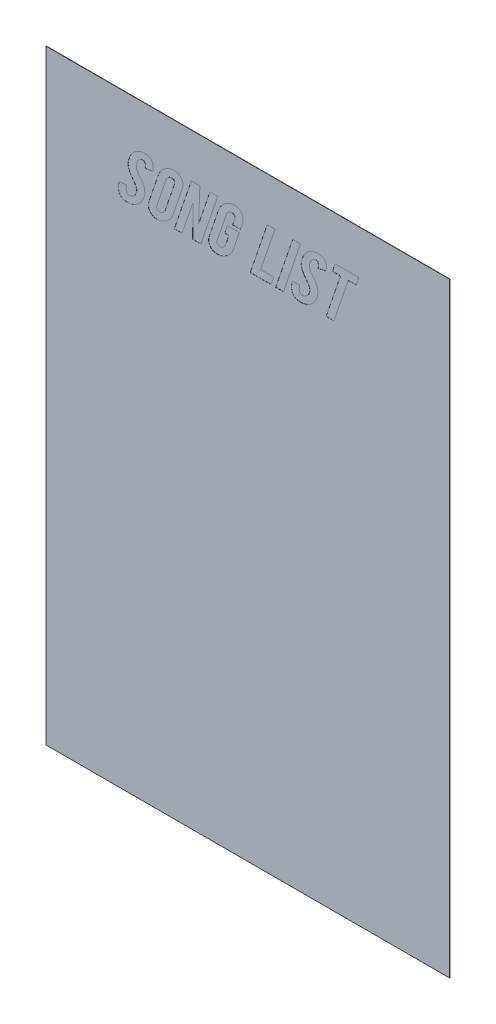
from build123d import *

# Parameters (mm, degrees)
SKETCH1_W           = 101.6
SKETCH1_H           = 152.4
BOSS_EXTRUDE1_DEPTH = 0.0762
CUT_EXTRUDE1_DEPTH  = 0.0254


with BuildPart() as part:
    # Sketch1 → Boss-Extrude1 (new body)
    with BuildSketch(Plane.XY):
        with Locations((50.8, 76.2)):
            Rectangle(SKETCH1_W, SKETCH1_H)
    extrude(amount=BOSS_EXTRUDE1_DEPTH)

    # Sketch2 → Cut-Extrude1 (cut)
    with BuildSketch(Plane.XY.offset(0.0762)):
        with BuildLine():
            add(Edge.make_bspline(
                [(24.709722411, 131.874145335), (24.672291046, 131.766544496), (24.597928769, 131.55278143), (24.461285746, 131.242755215), (24.307043652, 130.943876771), (24.128986602, 130.658993247), (23.935272763, 130.383775362), (23.719477586, 130.121712166), (23.484484784, 129.871420354), (23.314362951, 129.716392222), (23.228761989, 129.638386024)],
                knots=[0, 0, 0, 0, 0.000341658, 0.000678748, 0.001015434, 0.001349782, 0.001685778, 0.002024428, 0.002367376, 0.002714706, 0.002714706, 0.002714706, 0.002714706], degree=3))
            add(Edge.make_bspline(
                [(23.228761989, 129.638386024), (23.10934454, 129.537251061), (22.869964872, 129.334519767), (22.460691013, 129.094560959), (22.023340585, 128.890784152), (21.711749675, 128.799195889), (21.55347665, 128.752673506)],
                knots=[0, 0, 0, 0, 0.000468644, 0.000939426, 0.001418175, 0.001912397, 0.001912397, 0.001912397, 0.001912397], degree=3))
            add(Edge.make_bspline(
                [(21.55347665, 128.752673506), (21.467917096, 128.729833286), (21.293573471, 128.683292056), (21.021073564, 128.644679529), (20.738071611, 128.612486987), (20.545138284, 128.610499342), (20.446847384, 128.609486725)],
                knots=[0, 0, 0, 0, 0.000265422, 0.000540847, 0.000824579, 0.001119248, 0.001119248, 0.001119248, 0.001119248], degree=3))
            add(Edge.make_bspline(
                [(20.446847384, 128.609486725), (20.356799544, 128.61104227), (20.181805119, 128.614065236), (19.927836709, 128.637789315), (19.692262255, 128.681604133), (19.473121254, 128.737554558), (19.272291642, 128.81338792), (19.089103677, 128.905683719), (18.923020893, 129.013557405), (18.827105376, 129.10045869), (18.779744146, 129.143368866)],
                knots=[0, 0, 0, 0, 0.000270133, 0.000524963, 0.000764089, 0.000988351, 0.001202625, 0.001406624, 0.00160292, 0.001794392, 0.001794392, 0.001794392, 0.001794392], degree=3))
            add(Edge.make_bspline(
                [(18.779744146, 129.143368866), (18.707378095, 129.220497062), (18.560563145, 129.376973367), (18.401671353, 129.667104482), (18.280793624, 129.991910818), (18.211947949, 130.357430793), (18.188226135, 130.757331338), (18.216030933, 131.189121219), (18.287130708, 131.651703684), (18.370305281, 131.964822015), (18.413595092, 132.12779049)],
                knots=[0, 0, 0, 0, 0.000316164, 0.000641429, 0.00098379, 0.001352859, 0.001752491, 0.002182752, 0.00264853, 0.003154073, 0.003154073, 0.003154073, 0.003154073], degree=3))
            Line((18.413595092, 132.12779049), (20.256613518, 132.250522017))
            add(Edge.make_bspline(
                [(20.256613518, 132.250522017), (20.237932262, 132.162738665), (20.202025077, 131.994010554), (20.165518772, 131.748154924), (20.143001479, 131.520708023), (20.142345912, 131.312227877), (20.151032737, 131.121862369), (20.185969642, 130.951807287), (20.229754682, 130.797203394), (20.278204673, 130.706851251), (20.301615077, 130.663194272)],
                knots=[0, 0, 0, 0, 0.000269179, 0.000517388, 0.000745361, 0.000954015, 0.001142603, 0.001315507, 0.001474019, 0.001622217, 0.001622217, 0.001622217, 0.001622217], degree=3))
            add(Edge.make_bspline(
                [(20.301615077, 130.663194272), (20.339454787, 130.606584239), (20.412463753, 130.4973593), (20.572073641, 130.380484078), (20.760124381, 130.313586549), (20.894241247, 130.312127021), (20.964365322, 130.311363895)],
                knots=[0, 0, 0, 0, 0.00020292, 0.000391519, 0.000582368, 0.000791502, 0.000791502, 0.000791502, 0.000791502], degree=3))
            add(Edge.make_bspline(
                [(20.964365322, 130.311363895), (21.016305969, 130.315074019), (21.120966108, 130.322549899), (21.27635593, 130.353301089), (21.429703091, 130.403676782), (21.581357025, 130.47124548), (21.73063418, 130.558128058), (21.878951527, 130.661518258), (22.025945289, 130.781272986), (22.11809148, 130.872404958), (22.165088758, 130.918884953)],
                knots=[0, 0, 0, 0, 0.000156118, 0.000314577, 0.000473708, 0.000639446, 0.00081172, 0.000991027, 0.001181437, 0.001379642, 0.001379642, 0.001379642, 0.001379642], degree=3))
            add(Edge.make_bspline(
                [(22.165088758, 130.918884953), (22.222825837, 130.971729851), (22.339933249, 131.078914513), (22.485143716, 131.275755913), (22.609309407, 131.500900011), (22.671071076, 131.665931804), (22.70306195, 131.751413809)],
                knots=[0, 0, 0, 0, 0.000234335, 0.0004753, 0.000729809, 0.001003299, 0.001003299, 0.001003299, 0.001003299], degree=3))
            add(Edge.make_bspline(
                [(22.70306195, 131.751413809), (22.723618225, 131.817166814), (22.76402491, 131.946414984), (22.798926778, 132.145617003), (22.81030961, 132.343769362), (22.804052605, 132.541701628), (22.76835204, 132.737073685), (22.718803151, 132.933360088), (22.641669513, 133.128011558), (22.576651507, 133.25404525), (22.543510965, 133.318286299)],
                knots=[0, 0, 0, 0, 0.000206517, 0.000405943, 0.000604738, 0.000801279, 0.00099834, 0.001199281, 0.001407825, 0.001624631, 0.001624631, 0.001624631, 0.001624631], degree=3))
            add(Edge.make_bspline(
                [(22.543510965, 133.318286299), (22.510046704, 133.365295129), (22.439393573, 133.464544926), (22.328966453, 133.622077145), (22.208419143, 133.796517836), (22.075386514, 133.986702508), (21.929523055, 134.193539575), (21.773267937, 134.41758172), (21.604226071, 134.657360594), (21.489891055, 134.823671724), (21.430745123, 134.909705096)],
                knots=[0, 0, 0, 0, 0.00017311, 0.000365487, 0.000577137, 0.00080923, 0.001061768, 0.001336425, 0.001628677, 0.001941883, 0.001941883, 0.001941883, 0.001941883], degree=3))
            add(Edge.make_bspline(
                [(21.430745123, 134.909705096), (21.381779815, 134.984358315), (21.286184469, 135.130104369), (21.155517314, 135.349322945), (21.038079304, 135.561486001), (20.937512275, 135.769258999), (20.851507888, 135.970424267), (20.781381067, 136.166510557), (20.725283414, 136.356287374), (20.698995076, 136.482516229), (20.686173861, 136.544079926)],
                knots=[0, 0, 0, 0, 0.000267808, 0.000522843, 0.000765434, 0.000995062, 0.001215039, 0.001421434, 0.001619523, 0.001808111, 0.001808111, 0.001808111, 0.001808111], degree=3))
            add(Edge.make_bspline(
                [(20.686173861, 136.544079926), (20.669193581, 136.682301366), (20.634541463, 136.9643736), (20.658565049, 137.401378763), (20.732997963, 137.854878595), (20.826295013, 138.154831093), (20.874362202, 138.309368385)],
                knots=[0, 0, 0, 0, 0.000417057, 0.000851098, 0.001307434, 0.001792396, 0.001792396, 0.001792396, 0.001792396], degree=3))
            add(Edge.make_bspline(
                [(20.874362202, 138.309368385), (20.925258473, 138.448724014), (21.025670371, 138.723655022), (21.213724616, 139.114101969), (21.423710668, 139.481128068), (21.664306807, 139.819480872), (21.931557007, 140.132134243), (22.224896018, 140.418368015), (22.542669714, 140.682083935), (22.774393589, 140.831723521), (22.891250291, 140.9071857)],
                knots=[0, 0, 0, 0, 0.000444839, 0.000877612, 0.00129828, 0.001712032, 0.002121158, 0.002530513, 0.002940405, 0.003357397, 0.003357397, 0.003357397, 0.003357397], degree=3))
            add(Edge.make_bspline(
                [(22.891250291, 140.9071857), (22.965050562, 140.94972695), (23.111526209, 141.034161018), (23.339382974, 141.143471632), (23.573541691, 141.232021399), (23.81101357, 141.309927877), (24.055174024, 141.365263017), (24.302679848, 141.409746361), (24.555809628, 141.434251684), (24.72603876, 141.437421611), (24.811998683, 141.439022316)],
                knots=[0, 0, 0, 0, 0.000255502, 0.00050711, 0.000757067, 0.001006126, 0.001256191, 0.001507399, 0.001760193, 0.002018059, 0.002018059, 0.002018059, 0.002018059], degree=3))
            add(Edge.make_bspline(
                [(24.811998683, 141.439022316), (24.893205462, 141.438314231), (25.051185496, 141.436936721), (25.28060847, 141.412766706), (25.496150091, 141.379168793), (25.698465172, 141.330511884), (25.886152558, 141.264467081), (26.061354516, 141.18718418), (26.222864484, 141.094969981), (26.320274825, 141.021431106), (26.368643547, 140.984915667)],
                knots=[0, 0, 0, 0, 0.000243495, 0.000473696, 0.000691273, 0.000897658, 0.001096906, 0.001287359, 0.001471559, 0.001653231, 0.001653231, 0.001653231, 0.001653231], degree=3))
            add(Edge.make_bspline(
                [(26.368643547, 140.984915667), (26.436575522, 140.922434887), (26.572744169, 140.797193082), (26.734631026, 140.564417454), (26.8526206, 140.295709815), (26.933294945, 139.995726646), (26.976347633, 139.667582489), (26.972812017, 139.314142258), (26.935740259, 138.936691714), (26.87748973, 138.681150537), (26.847296501, 138.548694862)],
                knots=[0, 0, 0, 0, 0.000276267, 0.000553773, 0.000843091, 0.001152743, 0.001482834, 0.001832619, 0.002210997, 0.00261818, 0.00261818, 0.00261818, 0.00261818], degree=3))
            Line((26.847296501, 138.548694862), (24.899956277, 138.21731974))
            add(Edge.make_bspline(
                [(24.899956277, 138.21731974), (24.913999891, 138.279952334), (24.941065273, 138.400660234), (24.97382945, 138.577746948), (24.988537105, 138.744778813), (24.996869977, 138.900530965), (24.988297184, 139.045811834), (24.967607837, 139.179724953), (24.93892277, 139.305094522), (24.905889362, 139.380938526), (24.88972865, 139.418043176)],
                knots=[0, 0, 0, 0, 0.000192584, 0.000371155, 0.000539684, 0.000695265, 0.000838686, 0.000975231, 0.00110174, 0.00122291, 0.00122291, 0.00122291, 0.00122291], degree=3))
            add(Edge.make_bspline(
                [(24.88972865, 139.418043176), (24.862909409, 139.466976012), (24.809400019, 139.564606151), (24.667571299, 139.668399548), (24.487880751, 139.727572008), (24.355687652, 139.733786797), (24.284253119, 139.737145145)],
                knots=[0, 0, 0, 0, 0.000165675, 0.000330552, 0.000512328, 0.000726044, 0.000726044, 0.000726044, 0.000726044], degree=3))
            add(Edge.make_bspline(
                [(24.284253119, 139.737145145), (24.203002006, 139.731652082), (24.039320075, 139.7205862), (23.801605668, 139.627352381), (23.575540714, 139.479436327), (23.444589099, 139.346493525), (23.376039821, 139.27690192)],
                knots=[0, 0, 0, 0, 0.000243065, 0.000489659, 0.00075575, 0.001048053, 0.001048053, 0.001048053, 0.001048053], degree=3))
            add(Edge.make_bspline(
                [(23.376039821, 139.27690192), (23.32209428, 139.212529568), (23.212338689, 139.081559973), (23.07245548, 138.861534392), (22.949568643, 138.61993396), (22.886712505, 138.447182658), (22.854430833, 138.358460996)],
                knots=[0, 0, 0, 0, 0.000251733, 0.000512166, 0.0007802, 0.0010632, 0.0010632, 0.0010632, 0.0010632], degree=3))
            add(Edge.make_bspline(
                [(22.854430833, 138.358460996), (22.83242993, 138.287261166), (22.788732805, 138.145847518), (22.750875969, 137.928184684), (22.733979251, 137.710317892), (22.74036262, 137.4916247), (22.769376017, 137.271690156), (22.820935676, 137.050530225), (22.894732311, 136.827846721), (22.960139554, 136.683313474), (22.993526563, 136.60953674)],
                knots=[0, 0, 0, 0, 0.000223375, 0.000443656, 0.000661098, 0.000878011, 0.001098748, 0.001325506, 0.001558373, 0.001801179, 0.001801179, 0.001801179, 0.001801179], degree=3))
            add(Edge.make_bspline(
                [(22.993526563, 136.60953674), (23.024694576, 136.550392158), (23.091499772, 136.423622271), (23.217897826, 136.231746159), (23.373944734, 136.026134909), (23.490639897, 135.886956055), (23.551955009, 135.813827342)],
                knots=[0, 0, 0, 0, 0.000200472, 0.000429689, 0.000688244, 0.000974508, 0.000974508, 0.000974508, 0.000974508], degree=3))
            add(Edge.make_bspline(
                [(23.551955009, 135.813827342), (23.623172786, 135.729529926), (23.753219455, 135.575599283), (23.925319915, 135.363574725), (24.056235625, 135.192434731), (24.124455005, 135.088651994), (24.15333949, 135.044709775)],
                knots=[0, 0, 0, 0, 0.000331047, 0.000604505, 0.000819285, 0.000977003, 0.000977003, 0.000977003, 0.000977003], degree=3))
            add(Edge.make_bspline(
                [(24.15333949, 135.044709775), (24.22437429, 134.930001758), (24.362888658, 134.706326763), (24.529711589, 134.358207861), (24.664388786, 134.01411493), (24.723615337, 133.780609339), (24.752678445, 133.666025625)],
                knots=[0, 0, 0, 0, 0.000404482, 0.000788719, 0.001156459, 0.001510784, 0.001510784, 0.001510784, 0.001510784], degree=3))
            add(Edge.make_bspline(
                [(24.752678445, 133.666025625), (24.77405358, 133.564759315), (24.815265684, 133.369513867), (24.831011465, 133.170609221), (24.838590514, 133.074868771)],
                knots=[0, 0, 0, 0, 0.000310118, 0.00059792, 0.00059792, 0.00059792, 0.00059792], degree=3))
            add(Edge.make_bspline(
                [(24.838590514, 133.074868771), (24.842443398, 132.96644533), (24.849936965, 132.755569909), (24.830831381, 132.446228323), (24.788269467, 132.152376245), (24.735582178, 131.965746306), (24.709722411, 131.874145335)],
                knots=[0, 0, 0, 0, 0.000325296, 0.000632677, 0.000928629, 0.001213904, 0.001213904, 0.001213904, 0.001213904], degree=3))
        make_face()
        with BuildLine():
            add(Edge.make_bspline(
                [(32.269984455, 141.439022316), (32.371731093, 141.436340493), (32.56859248, 141.43115165), (32.85312674, 141.389346359), (33.117209655, 141.322830623), (33.360545798, 141.226828116), (33.581554257, 141.1004222), (33.781610762, 140.947676563), (33.961942549, 140.768520757), (34.114958404, 140.561387484), (34.247013626, 140.338333738), (34.344821213, 140.098850448), (34.41372219, 139.849707942), (34.447770673, 139.58824844), (34.451411916, 139.315800587), (34.423589059, 139.032162488), (34.366746316, 138.737140762), (34.304614838, 138.541325995), (34.272553866, 138.440282013)],
                knots=[0, 0, 0, 0, 0.000305119, 0.000590351, 0.00086074, 0.001120554, 0.001372494, 0.001622057, 0.001873731, 0.002132286, 0.002392607, 0.002649399, 0.002905948, 0.003166019, 0.003438105, 0.003721637, 0.004019702, 0.004337496, 0.004337496, 0.004337496, 0.004337496], degree=3))
            Line((34.272553866, 138.440282013), (31.948836961, 131.608227027))
            add(Edge.make_bspline(
                [(31.948836961, 131.608227027), (31.91097918, 131.505249156), (31.835533171, 131.30002663), (31.692397686, 131.005185541), (31.529254349, 130.720530465), (31.337014554, 130.450786166), (31.123703789, 130.190530859), (30.888929653, 129.939864624), (30.626657525, 129.704584374), (30.346102828, 129.482217194), (30.052130933, 129.279440845), (29.752982239, 129.100799666), (29.452137865, 128.948177358), (29.147472982, 128.824962144), (28.841203602, 128.728163151), (28.531710814, 128.660676821), (28.221020363, 128.618285669), (28.012695051, 128.612412342), (27.908924207, 128.609486725)],
                knots=[0, 0, 0, 0, 0.000328967, 0.000655592, 0.000981878, 0.001312171, 0.001647943, 0.001990891, 0.002341351, 0.00270394, 0.003064237, 0.003411886, 0.003748529, 0.004075199, 0.004396737, 0.004710903, 0.005024503, 0.005335752, 0.005335752, 0.005335752, 0.005335752], degree=3))
            add(Edge.make_bspline(
                [(27.908924207, 128.609486725), (27.807849187, 128.612137306), (27.612325328, 128.617264703), (27.329292075, 128.659570444), (27.066793637, 128.724768059), (26.825574189, 128.822714757), (26.606498013, 128.947682652), (26.406717801, 129.098659108), (26.229467533, 129.278803637), (26.07587397, 129.484420597), (25.946312393, 129.708344848), (25.850240982, 129.947679492), (25.783911173, 130.197718816), (25.749482836, 130.459567687), (25.74608104, 130.732682312), (25.773079794, 131.016609065), (25.83330553, 131.311096502), (25.894996857, 131.50713383), (25.926810051, 131.608227027)],
                knots=[0, 0, 0, 0, 0.000303076, 0.000586284, 0.000856672, 0.00111269, 0.00136463, 0.001611326, 0.001861558, 0.002120113, 0.002379411, 0.002635429, 0.002891447, 0.003153546, 0.003425631, 0.003709163, 0.004007628, 0.004325423, 0.004325423, 0.004325423, 0.004325423], degree=3))
            Line((25.926810051, 131.608227027), (28.250526956, 138.440282013))
            add(Edge.make_bspline(
                [(28.250526956, 138.440282013), (28.288394934, 138.543252481), (28.363861264, 138.748460252), (28.506845224, 139.04341136), (28.670844068, 139.328131715), (28.86097267, 139.599454051), (29.076484085, 139.857993927), (29.310306427, 140.10874547), (29.572739834, 140.343901125), (29.853261609, 140.566279443), (30.147198018, 140.769139774), (30.445990493, 140.947137825), (30.745097879, 141.100430717), (31.047247716, 141.223054908), (31.350513488, 141.320747244), (31.656128061, 141.387324325), (31.962615048, 141.430397457), (32.167567327, 141.436148467), (32.269984455, 141.439022316)],
                knots=[0, 0, 0, 0, 0.000328967, 0.000655592, 0.000981878, 0.001313846, 0.001648037, 0.001990985, 0.002341445, 0.002704034, 0.003064331, 0.00341198, 0.003746797, 0.004071572, 0.004389209, 0.004701378, 0.005008894, 0.005316057, 0.005316057, 0.005316057, 0.005316057], degree=3))
        make_face()
        with BuildLine():
            add(Edge.make_bspline(
                [(32.298621812, 138.411644657), (32.319266947, 138.482655707), (32.358259109, 138.616773232), (32.369435888, 138.81856732), (32.337712718, 139.004877967), (32.258390811, 139.168552911), (32.145964234, 139.307431784), (31.995818463, 139.405951112), (31.816407629, 139.46772605), (31.686194339, 139.472695033), (31.617461838, 139.475317888)],
                knots=[0, 0, 0, 0, 0.000221267, 0.000417903, 0.000600861, 0.000782026, 0.000957762, 0.001130231, 0.001313941, 0.00151932, 0.00151932, 0.00151932, 0.00151932], degree=3))
            add(Edge.make_bspline(
                [(31.617461838, 139.475317888), (31.545454018, 139.471999353), (31.399015343, 139.465250615), (31.183075873, 139.401502367), (30.969386555, 139.304070337), (30.764692814, 139.170230907), (30.576974362, 139.009729024), (30.417734606, 138.82805885), (30.288672846, 138.629644484), (30.232267664, 138.484416517), (30.204003756, 138.411644657)],
                knots=[0, 0, 0, 0, 0.000215568, 0.000438389, 0.000669977, 0.000918489, 0.001169423, 0.001408609, 0.001641269, 0.001874943, 0.001874943, 0.001874943, 0.001874943], degree=3))
            Line((30.204003756, 138.411644657), (27.900742105, 131.636864384))
            add(Edge.make_bspline(
                [(27.900742105, 131.636864384), (27.879856199, 131.566563148), (27.840445056, 131.43390661), (27.832224917, 131.232389947), (27.865572008, 131.046181974), (27.946894717, 130.880851259), (28.064502565, 130.744027367), (28.21420815, 130.641933965), (28.395219735, 130.584280277), (28.524215506, 130.577015789), (28.592129705, 130.573191152)],
                knots=[0, 0, 0, 0, 0.000219282, 0.000413779, 0.000599122, 0.000781174, 0.000959557, 0.001134865, 0.001317925, 0.001521463, 0.001521463, 0.001521463, 0.001521463], degree=3))
            add(Edge.make_bspline(
                [(28.592129705, 130.573191152), (28.664760045, 130.577480519), (28.810861587, 130.58610891), (29.027883036, 130.646305495), (29.238990998, 130.746089514), (29.440990049, 130.88102855), (29.627620306, 131.040700437), (29.782139339, 131.224890694), (29.913279715, 131.420194945), (29.967997866, 131.564635573), (29.995360161, 131.636864384)],
                knots=[0, 0, 0, 0, 0.000217788, 0.000438098, 0.000670542, 0.00091563, 0.001165016, 0.001404413, 0.001635349, 0.001866339, 0.001866339, 0.001866339, 0.001866339], degree=3))
            Line((29.995360161, 131.636864384), (32.298621812, 138.411644657))
        make_face(mode=Mode.SUBTRACT)
        Polygon((38.719526183, 141.308108687), (38.400424214, 132.868270702), (41.268250887, 141.308108687), (43.231955314, 141.308108687), (38.960898186, 128.740400354), (36.899008537, 128.740400354), (36.98287508, 136.787497454), (34.248007561, 128.740400354), (32.284303133, 128.740400354), (36.555360262, 141.308108687), align=None)
        with BuildLine():
            add(Edge.make_bspline(
                [(43.109223788, 128.609486725), (43.007474745, 128.61216151), (42.810608704, 128.617336735), (42.526107044, 128.659237417), (42.262524987, 128.725264024), (42.0201444, 128.822089649), (41.800399231, 128.948295561), (41.598944105, 129.098578776), (41.419557248, 129.278160016), (41.265917175, 129.48443903), (41.13664324, 129.708756363), (41.038812736, 129.946965422), (40.968888512, 130.195967414), (40.936560293, 130.45624245), (40.929191417, 130.727180681), (40.957208923, 131.008473978), (41.017334643, 131.299961051), (41.077689436, 131.494139106), (41.108699903, 131.593908349)],
                knots=[0, 0, 0, 0, 0.000305119, 0.000590351, 0.00086074, 0.001118655, 0.001370595, 0.001618922, 0.001870596, 0.002129151, 0.002388449, 0.002645242, 0.002899818, 0.003161916, 0.003429951, 0.003711446, 0.004007906, 0.004321199, 0.004321199, 0.004321199, 0.004321199], degree=3))
            Line((41.108699903, 131.593908349), (43.438553384, 138.448464115))
            add(Edge.make_bspline(
                [(43.438553384, 138.448464115), (43.475613384, 138.550800017), (43.549558226, 138.754988151), (43.693070472, 139.048515883), (43.858774718, 139.330762889), (44.047354957, 139.60233933), (44.261861242, 139.85995328), (44.497007564, 140.108738536), (44.758624336, 140.343991576), (45.039259319, 140.566272808), (45.333208285, 140.769076584), (45.632368059, 140.947694896), (45.933191127, 141.100379329), (46.237323902, 141.223133179), (46.5420543, 141.320387315), (46.849533135, 141.38781456), (47.158855159, 141.430323997), (47.366510249, 141.436123877), (47.470284036, 141.439022316)],
                knots=[0, 0, 0, 0, 0.000326324, 0.000651105, 0.000978421, 0.001307541, 0.001641733, 0.001983195, 0.002333655, 0.002696244, 0.003056541, 0.00340419, 0.003740833, 0.004067503, 0.00438709, 0.004699258, 0.00501083, 0.00532208, 0.00532208, 0.00532208, 0.00532208], degree=3))
            add(Edge.make_bspline(
                [(47.470284036, 141.439022316), (47.571333583, 141.436364864), (47.76758328, 141.431203792), (48.051599535, 141.388757181), (48.313264121, 141.313797244), (48.5556777, 141.214981807), (48.773454427, 141.081936743), (48.971383799, 140.923373242), (49.143683028, 140.732081368), (49.293561064, 140.516683252), (49.41845449, 140.281984781), (49.512514496, 140.033679563), (49.576494173, 139.775530732), (49.609970789, 139.506987386), (49.607790284, 139.228450624), (49.579793194, 138.939761129), (49.517023516, 138.642162661), (49.455405034, 138.443909689), (49.423760836, 138.342096792)],
                knots=[0, 0, 0, 0, 0.000303076, 0.000588608, 0.000858626, 0.001118093, 0.001371375, 0.001621515, 0.001876345, 0.00214078, 0.00240706, 0.002671851, 0.002935288, 0.003203212, 0.003481404, 0.003769206, 0.004072089, 0.004391845, 0.004391845, 0.004391845, 0.004391845], degree=3))
            Line((49.423760836, 138.342096792), (48.93692578, 136.90613793))
            Line((48.93692578, 136.90613793), (46.973221353, 136.90613793))
            Line((46.973221353, 136.90613793), (47.472329562, 138.376870725))
            add(Edge.make_bspline(
                [(47.472329562, 138.376870725), (47.493564942, 138.44922314), (47.534077896, 138.587257406), (47.547931049, 138.794693454), (47.514999674, 138.986744799), (47.436589383, 139.156635881), (47.322481249, 139.299944665), (47.172929675, 139.404691828), (46.99187603, 139.464948115), (46.86186916, 139.47173426), (46.793215114, 139.475317888)],
                knots=[0, 0, 0, 0, 0.000225732, 0.000430652, 0.000617636, 0.000804362, 0.000986138, 0.00116092, 0.00134463, 0.001550203, 0.001550203, 0.001550203, 0.001550203], degree=3))
            add(Edge.make_bspline(
                [(46.793215114, 139.475317888), (46.721308514, 139.470904579), (46.575976275, 139.461984727), (46.359374689, 139.403210347), (46.149436517, 139.29833039), (45.944319487, 139.164381169), (45.757405938, 139.002117138), (45.598998256, 138.819019746), (45.471036344, 138.619801759), (45.414245597, 138.474137753), (45.385893608, 138.40141703)],
                knots=[0, 0, 0, 0, 0.000215752, 0.000436062, 0.000667532, 0.000917161, 0.001169434, 0.001407278, 0.001641667, 0.001875341, 0.001875341, 0.001875341, 0.001875341], degree=3))
            Line((45.385893608, 138.40141703), (43.088768533, 131.640955435))
            add(Edge.make_bspline(
                [(43.088768533, 131.640955435), (43.068108257, 131.569945764), (43.029087496, 131.435830842), (43.018065777, 131.233343214), (43.049459911, 131.046435263), (43.128667564, 130.881038234), (43.244231516, 130.744201793), (43.392369529, 130.64143928), (43.572414152, 130.584586838), (43.70067638, 130.577109247), (43.767882981, 130.573191152)],
                knots=[0, 0, 0, 0, 0.000221267, 0.000417903, 0.000602874, 0.000784038, 0.000961092, 0.001134708, 0.001317769, 0.001519271, 0.001519271, 0.001519271, 0.001519271], degree=3))
            add(Edge.make_bspline(
                [(43.767882981, 130.573191152), (43.840494499, 130.577551902), (43.987216929, 130.586363448), (44.205142213, 130.645834169), (44.418076994, 130.746918433), (44.622792447, 130.883087003), (44.813340902, 131.044238803), (44.971419311, 131.231573493), (45.102747399, 131.432189925), (45.159300218, 131.579721189), (45.18747764, 131.653228587)],
                knots=[0, 0, 0, 0, 0.000217788, 0.000440074, 0.000672518, 0.000922148, 0.001175966, 0.001418246, 0.001655457, 0.001891012, 0.001891012, 0.001891012, 0.001891012], degree=3))
            Line((45.18747764, 131.653228587), (46.022052021, 134.107859121))
            Line((46.022052021, 134.107859121), (44.974742994, 134.107859121))
            Line((44.974742994, 134.107859121), (45.641584289, 136.071563548))
            Line((45.641584289, 136.071563548), (48.652597743, 136.071563548))
            Line((48.652597743, 136.071563548), (47.145045491, 131.636864384))
            add(Edge.make_bspline(
                [(47.145045491, 131.636864384), (47.107328369, 131.532471014), (47.032074107, 131.324182423), (46.886581973, 131.025589003), (46.721055052, 130.737633463), (46.529996658, 130.46263883), (46.3136226, 130.200833871), (46.077092598, 129.948665465), (45.814834074, 129.710623938), (45.534073341, 129.486487731), (45.240755151, 129.281294192), (44.940948083, 129.102941903), (44.640719925, 128.950494793), (44.337180132, 128.827591163), (44.033749506, 128.727558362), (43.726487062, 128.661069074), (43.418632965, 128.618115831), (43.212322601, 128.612362046), (43.109223788, 128.609486725)],
                knots=[0, 0, 0, 0, 0.000332786, 0.000663985, 0.000994835, 0.001328482, 0.001667132, 0.002012971, 0.002364807, 0.00272867, 0.003090132, 0.003437781, 0.003774424, 0.004099199, 0.004419407, 0.004731576, 0.00504112, 0.005350326, 0.005350326, 0.005350326, 0.005350326], degree=3))
        make_face()
        Polygon((56.642420131, 128.740400354), (51.39769289, 128.740400354), (55.668750019, 141.308108687), (57.632454446, 141.308108687), (54.028238613, 130.704104781), (57.309261426, 130.704104781), align=None)
        Polygon((59.776165113, 128.740400354), (57.812460686, 128.740400354), (62.083517814, 141.308108687), (64.047222242, 141.308108687), align=None)
        with BuildLine():
            add(Edge.make_bspline(
                [(68.303960692, 131.874145335), (68.266529327, 131.766544496), (68.19216705, 131.55278143), (68.055524027, 131.242755215), (67.901281933, 130.943876771), (67.723224883, 130.658993247), (67.529511044, 130.383775362), (67.313715867, 130.121712166), (67.078723066, 129.871420354), (66.908601233, 129.716392222), (66.82300027, 129.638386024)],
                knots=[0, 0, 0, 0, 0.000341658, 0.000678748, 0.001015434, 0.001349782, 0.001685778, 0.002024428, 0.002367376, 0.002714706, 0.002714706, 0.002714706, 0.002714706], degree=3))
            add(Edge.make_bspline(
                [(66.82300027, 129.638386024), (66.703582821, 129.537251061), (66.464203153, 129.334519767), (66.054929294, 129.094560959), (65.617578867, 128.890784152), (65.305987956, 128.799195889), (65.147714931, 128.752673506)],
                knots=[0, 0, 0, 0, 0.000468644, 0.000939426, 0.001418175, 0.001912397, 0.001912397, 0.001912397, 0.001912397], degree=3))
            add(Edge.make_bspline(
                [(65.147714931, 128.752673506), (65.062155377, 128.729833286), (64.887811752, 128.683292056), (64.615311846, 128.644679529), (64.332309893, 128.612486987), (64.139376566, 128.610499342), (64.041085665, 128.609486725)],
                knots=[0, 0, 0, 0, 0.000265422, 0.000540847, 0.000824579, 0.001119248, 0.001119248, 0.001119248, 0.001119248], degree=3))
            add(Edge.make_bspline(
                [(64.041085665, 128.609486725), (63.951037825, 128.61104227), (63.7760434, 128.614065236), (63.52207499, 128.637789315), (63.286500537, 128.681604133), (63.067359535, 128.737554558), (62.866529924, 128.81338792), (62.683341958, 128.905683719), (62.517259174, 129.013557405), (62.421343657, 129.10045869), (62.373982428, 129.143368866)],
                knots=[0, 0, 0, 0, 0.000270133, 0.000524963, 0.000764089, 0.000988351, 0.001202625, 0.001406624, 0.00160292, 0.001794392, 0.001794392, 0.001794392, 0.001794392], degree=3))
            add(Edge.make_bspline(
                [(62.373982428, 129.143368866), (62.301616377, 129.220497062), (62.154801427, 129.376973367), (61.995909634, 129.667104482), (61.875031905, 129.991910818), (61.80618623, 130.357430793), (61.782464416, 130.757331338), (61.810269215, 131.189121219), (61.881368989, 131.651703684), (61.964543562, 131.964822015), (62.007833373, 132.12779049)],
                knots=[0, 0, 0, 0, 0.000316164, 0.000641429, 0.00098379, 0.001352859, 0.001752491, 0.002182752, 0.00264853, 0.003154073, 0.003154073, 0.003154073, 0.003154073], degree=3))
            Line((62.007833373, 132.12779049), (63.850851799, 132.250522017))
            add(Edge.make_bspline(
                [(63.850851799, 132.250522017), (63.832170543, 132.162738665), (63.796263358, 131.994010554), (63.759757053, 131.748154924), (63.73723976, 131.520708023), (63.736584193, 131.312227877), (63.745271018, 131.121862369), (63.780207923, 130.951807287), (63.823992963, 130.797203394), (63.872442954, 130.706851251), (63.895853359, 130.663194272)],
                knots=[0, 0, 0, 0, 0.000269179, 0.000517388, 0.000745361, 0.000954015, 0.001142603, 0.001315507, 0.001474019, 0.001622217, 0.001622217, 0.001622217, 0.001622217], degree=3))
            add(Edge.make_bspline(
                [(63.895853359, 130.663194272), (63.933693068, 130.606584239), (64.006702034, 130.4973593), (64.166311922, 130.380484078), (64.354362662, 130.313586549), (64.488479528, 130.312127021), (64.558603603, 130.311363895)],
                knots=[0, 0, 0, 0, 0.00020292, 0.000391519, 0.000582368, 0.000791502, 0.000791502, 0.000791502, 0.000791502], degree=3))
            add(Edge.make_bspline(
                [(64.558603603, 130.311363895), (64.61054425, 130.315074019), (64.715204389, 130.322549899), (64.870594211, 130.353301089), (65.023941372, 130.403676782), (65.175595306, 130.47124548), (65.324872461, 130.558128058), (65.473189808, 130.661518258), (65.62018357, 130.781272986), (65.712329762, 130.872404958), (65.759327039, 130.918884953)],
                knots=[0, 0, 0, 0, 0.000156118, 0.000314577, 0.000473708, 0.000639446, 0.00081172, 0.000991027, 0.001181437, 0.001379642, 0.001379642, 0.001379642, 0.001379642], degree=3))
            add(Edge.make_bspline(
                [(65.759327039, 130.918884953), (65.817064118, 130.971729851), (65.934171531, 131.078914513), (66.079381997, 131.275755913), (66.203547689, 131.500900011), (66.265309357, 131.665931804), (66.297300231, 131.751413809)],
                knots=[0, 0, 0, 0, 0.000234335, 0.0004753, 0.000729809, 0.001003299, 0.001003299, 0.001003299, 0.001003299], degree=3))
            add(Edge.make_bspline(
                [(66.297300231, 131.751413809), (66.317856506, 131.817166814), (66.358263191, 131.946414984), (66.393165059, 132.145617003), (66.404547891, 132.343769362), (66.398290886, 132.541701628), (66.362590321, 132.737073685), (66.313041433, 132.933360088), (66.235907794, 133.128011558), (66.170889788, 133.25404525), (66.137749246, 133.318286299)],
                knots=[0, 0, 0, 0, 0.000206517, 0.000405943, 0.000604738, 0.000801279, 0.00099834, 0.001199281, 0.001407825, 0.001624631, 0.001624631, 0.001624631, 0.001624631], degree=3))
            add(Edge.make_bspline(
                [(66.137749246, 133.318286299), (66.104284986, 133.365295129), (66.033631854, 133.464544926), (65.923204734, 133.622077145), (65.802657424, 133.796517836), (65.669624795, 133.986702508), (65.523761336, 134.193539575), (65.367506218, 134.41758172), (65.198464352, 134.657360594), (65.084129336, 134.823671724), (65.024983404, 134.909705096)],
                knots=[0, 0, 0, 0, 0.00017311, 0.000365487, 0.000577137, 0.00080923, 0.001061768, 0.001336425, 0.001628677, 0.001941883, 0.001941883, 0.001941883, 0.001941883], degree=3))
            add(Edge.make_bspline(
                [(65.024983404, 134.909705096), (64.976018096, 134.984358315), (64.88042275, 135.130104369), (64.749755595, 135.349322945), (64.632317585, 135.561486001), (64.531750556, 135.769258999), (64.44574617, 135.970424267), (64.375619348, 136.166510557), (64.319521695, 136.356287374), (64.293233357, 136.482516229), (64.280412142, 136.544079926)],
                knots=[0, 0, 0, 0, 0.000267808, 0.000522843, 0.000765434, 0.000995062, 0.001215039, 0.001421434, 0.001619523, 0.001808111, 0.001808111, 0.001808111, 0.001808111], degree=3))
            add(Edge.make_bspline(
                [(64.280412142, 136.544079926), (64.263431862, 136.682301366), (64.228779744, 136.9643736), (64.252803331, 137.401378763), (64.327236244, 137.854878595), (64.420533294, 138.154831093), (64.468600483, 138.309368385)],
                knots=[0, 0, 0, 0, 0.000417057, 0.000851098, 0.001307434, 0.001792396, 0.001792396, 0.001792396, 0.001792396], degree=3))
            add(Edge.make_bspline(
                [(64.468600483, 138.309368385), (64.519496755, 138.448724014), (64.619908653, 138.723655022), (64.807962897, 139.114101969), (65.017948949, 139.481128068), (65.258545089, 139.819480872), (65.525795288, 140.132134243), (65.819134299, 140.418368015), (66.136907995, 140.682083935), (66.36863187, 140.831723521), (66.485488572, 140.9071857)],
                knots=[0, 0, 0, 0, 0.000444839, 0.000877612, 0.00129828, 0.001712032, 0.002121158, 0.002530513, 0.002940405, 0.003357397, 0.003357397, 0.003357397, 0.003357397], degree=3))
            add(Edge.make_bspline(
                [(66.485488572, 140.9071857), (66.559288843, 140.94972695), (66.70576449, 141.034161018), (66.933621255, 141.143471632), (67.167779973, 141.232021399), (67.405251852, 141.309927877), (67.649412305, 141.365263017), (67.896918129, 141.409746361), (68.150047909, 141.434251684), (68.320277041, 141.437421611), (68.406236965, 141.439022316)],
                knots=[0, 0, 0, 0, 0.000255502, 0.00050711, 0.000757067, 0.001006126, 0.001256191, 0.001507399, 0.001760193, 0.002018059, 0.002018059, 0.002018059, 0.002018059], degree=3))
            add(Edge.make_bspline(
                [(68.406236965, 141.439022316), (68.487443743, 141.438314231), (68.645423777, 141.436936721), (68.874846751, 141.412766706), (69.090388372, 141.379168793), (69.292703454, 141.330511884), (69.480390839, 141.264467081), (69.655592797, 141.18718418), (69.817102765, 141.094969981), (69.914513107, 141.021431106), (69.962881828, 140.984915667)],
                knots=[0, 0, 0, 0, 0.000243495, 0.000473696, 0.000691273, 0.000897658, 0.001096906, 0.001287359, 0.001471559, 0.001653231, 0.001653231, 0.001653231, 0.001653231], degree=3))
            add(Edge.make_bspline(
                [(69.962881828, 140.984915667), (70.030813803, 140.922434887), (70.16698245, 140.797193082), (70.328869307, 140.564417454), (70.446858881, 140.295709815), (70.527533226, 139.995726646), (70.570585915, 139.667582489), (70.567050298, 139.314142258), (70.52997854, 138.936691714), (70.471728011, 138.681150537), (70.441534782, 138.548694862)],
                knots=[0, 0, 0, 0, 0.000276267, 0.000553773, 0.000843091, 0.001152743, 0.001482834, 0.001832619, 0.002210997, 0.00261818, 0.00261818, 0.00261818, 0.00261818], degree=3))
            Line((70.441534782, 138.548694862), (68.494194559, 138.21731974))
            add(Edge.make_bspline(
                [(68.494194559, 138.21731974), (68.508238172, 138.279952334), (68.535303555, 138.400660234), (68.568067731, 138.577746948), (68.582775386, 138.744778813), (68.591108259, 138.900530965), (68.582535465, 139.045811834), (68.561846118, 139.179724953), (68.533161051, 139.305094522), (68.500127643, 139.380938526), (68.483966932, 139.418043176)],
                knots=[0, 0, 0, 0, 0.000192584, 0.000371155, 0.000539684, 0.000695265, 0.000838686, 0.000975231, 0.00110174, 0.00122291, 0.00122291, 0.00122291, 0.00122291], degree=3))
            add(Edge.make_bspline(
                [(68.483966932, 139.418043176), (68.45714769, 139.466976012), (68.403638301, 139.564606151), (68.26180958, 139.668399548), (68.082119033, 139.727572008), (67.949925933, 139.733786797), (67.8784914, 139.737145145)],
                knots=[0, 0, 0, 0, 0.000165675, 0.000330552, 0.000512328, 0.000726044, 0.000726044, 0.000726044, 0.000726044], degree=3))
            add(Edge.make_bspline(
                [(67.8784914, 139.737145145), (67.797240287, 139.731652082), (67.633558357, 139.7205862), (67.395843949, 139.627352381), (67.169778995, 139.479436327), (67.03882738, 139.346493525), (66.970278102, 139.27690192)],
                knots=[0, 0, 0, 0, 0.000243065, 0.000489659, 0.00075575, 0.001048053, 0.001048053, 0.001048053, 0.001048053], degree=3))
            add(Edge.make_bspline(
                [(66.970278102, 139.27690192), (66.916332562, 139.212529568), (66.80657697, 139.081559973), (66.666693762, 138.861534392), (66.543806924, 138.61993396), (66.480950787, 138.447182658), (66.448669114, 138.358460996)],
                knots=[0, 0, 0, 0, 0.000251733, 0.000512166, 0.0007802, 0.0010632, 0.0010632, 0.0010632, 0.0010632], degree=3))
            add(Edge.make_bspline(
                [(66.448669114, 138.358460996), (66.426668211, 138.287261166), (66.382971086, 138.145847518), (66.34511425, 137.928184684), (66.328217532, 137.710317892), (66.334600902, 137.4916247), (66.363614299, 137.271690156), (66.415173957, 137.050530225), (66.488970592, 136.827846721), (66.554377836, 136.683313474), (66.587764844, 136.60953674)],
                knots=[0, 0, 0, 0, 0.000223375, 0.000443656, 0.000661098, 0.000878011, 0.001098748, 0.001325506, 0.001558373, 0.001801179, 0.001801179, 0.001801179, 0.001801179], degree=3))
            add(Edge.make_bspline(
                [(66.587764844, 136.60953674), (66.618932857, 136.550392158), (66.685738053, 136.423622271), (66.812136108, 136.231746159), (66.968183015, 136.026134909), (67.084878178, 135.886956055), (67.146193291, 135.813827342)],
                knots=[0, 0, 0, 0, 0.000200472, 0.000429689, 0.000688244, 0.000974508, 0.000974508, 0.000974508, 0.000974508], degree=3))
            add(Edge.make_bspline(
                [(67.146193291, 135.813827342), (67.217411068, 135.729529926), (67.347457736, 135.575599283), (67.519558196, 135.363574725), (67.650473906, 135.192434731), (67.718693286, 135.088651994), (67.747577771, 135.044709775)],
                knots=[0, 0, 0, 0, 0.000331047, 0.000604505, 0.000819285, 0.000977003, 0.000977003, 0.000977003, 0.000977003], degree=3))
            add(Edge.make_bspline(
                [(67.747577771, 135.044709775), (67.818612572, 134.930001758), (67.957126939, 134.706326763), (68.12394987, 134.358207861), (68.258627067, 134.01411493), (68.317853619, 133.780609339), (68.346916727, 133.666025625)],
                knots=[0, 0, 0, 0, 0.000404482, 0.000788719, 0.001156459, 0.001510784, 0.001510784, 0.001510784, 0.001510784], degree=3))
            add(Edge.make_bspline(
                [(68.346916727, 133.666025625), (68.368291861, 133.564759315), (68.409503965, 133.369513867), (68.425249746, 133.170609221), (68.432828795, 133.074868771)],
                knots=[0, 0, 0, 0, 0.000310118, 0.00059792, 0.00059792, 0.00059792, 0.00059792], degree=3))
            add(Edge.make_bspline(
                [(68.432828795, 133.074868771), (68.436681679, 132.96644533), (68.444175247, 132.755569909), (68.425069662, 132.446228323), (68.382507748, 132.152376245), (68.32982046, 131.965746306), (68.303960692, 131.874145335)],
                knots=[0, 0, 0, 0, 0.000325296, 0.000632677, 0.000928629, 0.001213904, 0.001213904, 0.001213904, 0.001213904], degree=3))
        make_face()
        Polygon((74.115298481, 139.34440426), (72.100455918, 139.34440426), (72.767297213, 141.308108687), (78.75455019, 141.308108687), (78.087708895, 139.34440426), (76.079002908, 139.34440426), (72.474787074, 128.740400354), (70.511082647, 128.740400354), align=None)
    extrude(amount=-CUT_EXTRUDE1_DEPTH, mode=Mode.SUBTRACT)


solid = part.part
